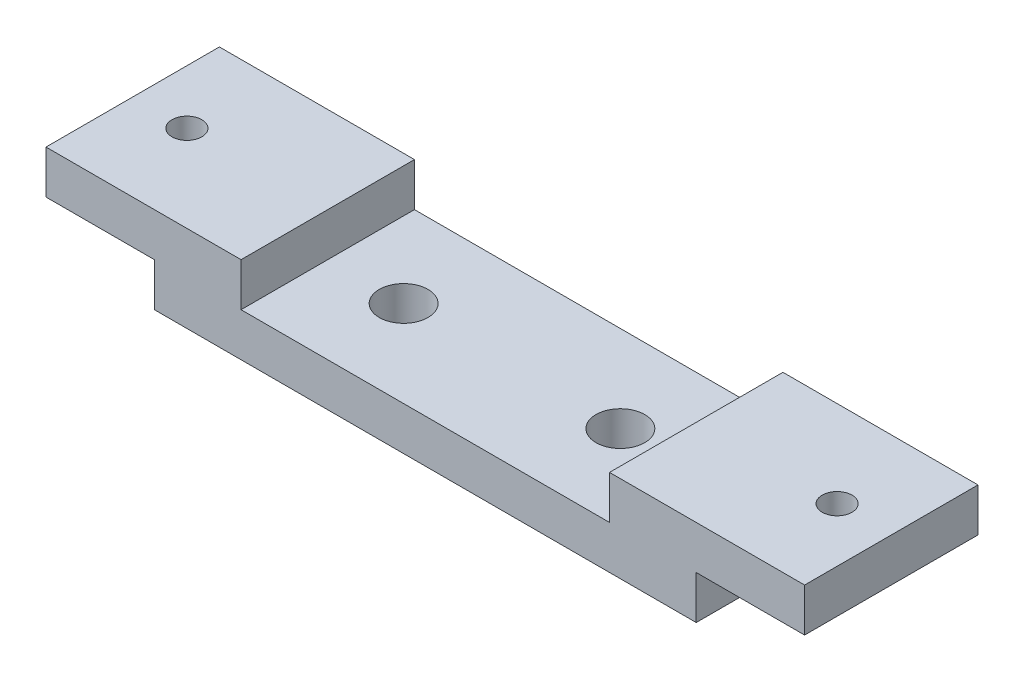
from build123d import *

# Parameters (mm, degrees)
AUFSATZ_LINEAR_AUSTRAGEN1_DEPTH  = 32
F_9_0_9_DURCHMESSER_BOHRUNG1_D   = 9
F_5_5_5_5_DURCHMESSER_BOHRUNG1_D = 5.5


with BuildPart() as part:
    # Skizze1 → Aufsatz-Linear austragen1 (new body)
    with BuildSketch(Plane.XY):
        Polygon((-70, 16), (-34, 16), (-34, 8), (34, 8), (34, 16), (70, 16), (70, 8), (50, 8), (50, 0), (-50, 0), (-50, 8), (-70, 8), align=None)
    extrude(amount=AUFSATZ_LINEAR_AUSTRAGEN1_DEPTH)

    # Ø9.0 (9) Durchmesser Bohrung1 (through all)
    with Locations(Plane(origin=(20, 8, 16), x_dir=(0, 0, 1), z_dir=(0, 1, 0))):
        with Locations((0, 0), (0, -40)):
            Hole(F_9_0_9_DURCHMESSER_BOHRUNG1_D / 2)

    # Ø5.5 (5.5) Durchmesser Bohrung1 (through all)
    with Locations(Plane(origin=(-60, 8, 16), x_dir=(-1, 0, 0), z_dir=(0, -1, 0))):
        with Locations((0, 0), (-120, 0)):
            Hole(F_5_5_5_5_DURCHMESSER_BOHRUNG1_D / 2)


solid = part.part
